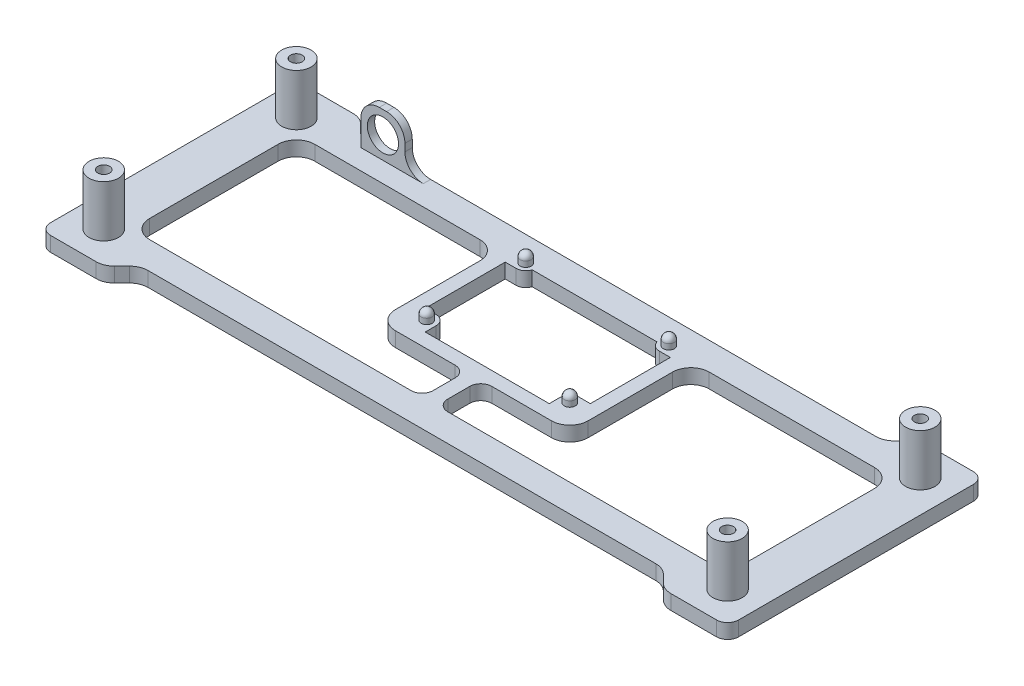
from build123d import *

# Parameters (mm, degrees)
SKETCH2_R           = 1.6
SKETCH2_W           = 162.5
SKETCH2_H           = 45
BOSS_EXTRUDE2_DEPTH = 4
FILLET3_R           = 3
FILLET4_R           = 5
BOSS_EXTRUDE3_DEPTH = 4
FILLET5_R           = 5
SKETCH7_W           = 12
SKETCH7_H           = 2
BOSS_EXTRUDE4_DEPTH = 12
CUT_EXTRUDE3_REACH  = 67
SKETCH8_R           = 4.25
FILLET6_R           = 5
FILLET7_R           = 3
SKETCH9_R           = 1.5
BOSS_EXTRUDE5_DEPTH = 3
FILLET8_R           = 1.5
SKETCH10_R          = 4
SKETCH10_R_2        = 1.6
BOSS_EXTRUDE6_DEPTH = 14


with BuildPart() as part:
    # Sketch2 → Boss-Extrude2 (new body)
    with BuildSketch(Plane(origin=(0, 0, 0), x_dir=(1, 0, 0), z_dir=(0, 1, 0))):
        Polygon((-93.75, -35), (-76.25, -35), (-71.25, -30), (71.25, -30), (76.25, -35), (93.75, -35), (93.75, 35), (76.25, 35), (71.25, 30), (-71.25, 30), (-76.25, 35), (-93.75, 35), align=None)
        with Locations((-85, 26.25)):
            Circle(SKETCH2_R, mode=Mode.SUBTRACT)
        with Locations((85, 26.25)):
            Circle(SKETCH2_R, mode=Mode.SUBTRACT)
        with Locations((85, -26.25)):
            Circle(SKETCH2_R, mode=Mode.SUBTRACT)
        with Locations((-85, -26.25)):
            Circle(SKETCH2_R, mode=Mode.SUBTRACT)
        Rectangle(SKETCH2_W, SKETCH2_H, mode=Mode.SUBTRACT)
    extrude(amount=BOSS_EXTRUDE2_DEPTH)

    # Fillet3
    fillet3_edges = [part.edges().sort_by_distance(p)[0] for p in [
        (-93.75, 2, -35),
        (93.75, 2, -35),
        (93.75, 2, 35),
        (-93.75, 2, 35),
    ]]
    fillet(fillet3_edges, radius=FILLET3_R)

    # Fillet4
    fillet4_edges = [part.edges().sort_by_distance(p)[0] for p in [
        (-76.25, 2, -35),
        (-71.25, 2, -30),
        (71.25, 2, -30),
        (76.25, 2, -35),
        (76.25, 2, 35),
        (71.25, 2, 30),
        (-71.25, 2, 30),
        (-76.25, 2, 35),
        (81.25, 2, -22.5),
        (-81.25, 2, -22.5),
        (-81.25, 2, 22.5),
        (81.25, 2, 22.5),
    ]]
    fillet(fillet4_edges, radius=FILLET4_R)

    # Sketch5 → Boss-Extrude3 (add)
    with BuildSketch(Plane(origin=(0, 0, 0), x_dir=(1, 0, 0), z_dir=(0, 1, 0))):
        Polygon((-26.25, -10.5), (-2, -10.5), (-2, -25.93943087), (2, -25.93943087), (2, -10.5), (26.25, -10.5), (26.25, 30), (-26.25, 30), align=None)
        with BuildLine():
            Line((-16.9, 26.25), (16.9, 26.25))
            Line((16.9, 26.25), (16.9, 23.25))
            ThreePointArc((16.9, 23.25), (17.661522369, 21.411522369), (19.5, 20.65))
            Line((19.5, 20.65), (22.5, 20.65))
            Line((22.5, 20.65), (22.5, -1.15))
            Line((22.5, -1.15), (19.5, -1.15))
            ThreePointArc((19.5, -1.15), (17.661522369, -1.911522369), (16.9, -3.75))
            Line((16.9, -3.75), (16.9, -6.75))
            Line((16.9, -6.75), (-16.9, -6.75))
            Line((-16.9, -6.75), (-16.9, -3.75))
            ThreePointArc((-16.9, -3.75), (-17.661522369, -1.911522369), (-19.5, -1.15))
            Line((-19.5, -1.15), (-22.5, -1.15))
            Line((-22.5, -1.15), (-22.5, 20.65))
            Line((-22.5, 20.65), (-19.5, 20.65))
            ThreePointArc((-19.5, 20.65), (-17.661522369, 21.411522369), (-16.9, 23.25))
            Line((-16.9, 23.25), (-16.9, 26.25))
        make_face(mode=Mode.SUBTRACT)
    extrude(amount=BOSS_EXTRUDE3_DEPTH)

    # Fillet5
    fillet5_edges = [part.edges().sort_by_distance(p)[0] for p in [
        (-26.25, 2, -22.5),
        (26.25, 2, -22.5),
        (26.25, 2, 10.5),
        (-26.25, 2, 10.5),
    ]]
    fillet(fillet5_edges, radius=FILLET5_R)

    # Sketch7 → Boss-Extrude4 (add)
    with BuildSketch(Plane(origin=(0, 4, 0), x_dir=(1, 0, 0), z_dir=(0, 1, 0))):
        with Locations((-63.178932188, 29)):
            Rectangle(SKETCH7_W, SKETCH7_H)
    extrude(amount=BOSS_EXTRUDE4_DEPTH)

    # Sketch8 → Cut-Extrude3 (cut, up to next)
    with BuildSketch(Plane(origin=(0, 0, -30), x_dir=(-1, 0, 0), z_dir=(0, 0, -1)), mode=Mode.PRIVATE) as cut_extrude3_sk1:
        with Locations((63.178932188, 10)):
            Circle(SKETCH8_R)
    cut_extrude3_tool1 = extrude(cut_extrude3_sk1.sketch, amount=-CUT_EXTRUDE3_REACH, mode=Mode.PRIVATE) & part.part
    add(cut_extrude3_tool1.solids().sort_by_distance((-63.178932, 10, -30))[0], mode=Mode.SUBTRACT)

    # Fillet6
    fillet6_edges = [part.edges().sort_by_distance(p)[0] for p in [
        (-57.178932188, 4, -29),
        (-69.178932188, 16, -29),
        (-57.178932188, 16, -29),
    ]]
    fillet(fillet6_edges, radius=FILLET6_R)

    # Fillet7
    fillet7_edges = [part.edges().sort_by_distance(p)[0] for p in [
        (2, 2, 22.5),
        (-2, 2, 22.5),
        (-2, 2, 10.5),
        (2, 2, 10.5),
    ]]
    fillet(fillet7_edges, radius=FILLET7_R)

    # Sketch9 → Boss-Extrude5 (add)
    with BuildSketch(Plane(origin=(0, 4, 0), x_dir=(1, 0, 0), z_dir=(0, 1, 0))):
        with Locations((-19.5, -3.75)):
            Circle(SKETCH9_R)
        with Locations((-19.5, 23.25)):
            Circle(SKETCH9_R)
        with Locations((19.5, 23.25)):
            Circle(SKETCH9_R)
        with Locations((19.5, -3.75)):
            Circle(SKETCH9_R)
    extrude(amount=BOSS_EXTRUDE5_DEPTH)

    # Fillet8
    fillet8_edges = [part.edges().sort_by_distance(p)[0] for p in [
        (-21, 7, 3.75),
        (-21, 7, -23.25),
        (18, 7, -23.25),
        (18, 7, 3.75),
    ]]
    fillet(fillet8_edges, radius=FILLET8_R)

    # Sketch10 → Boss-Extrude6 (add)
    with BuildSketch(Plane(origin=(0, 4, 0), x_dir=(1, 0, 0), z_dir=(0, 1, 0))):
        with Locations((-85, 26.25)):
            Circle(SKETCH10_R)
        with Locations((-85, 26.25)):
            Circle(SKETCH10_R_2, mode=Mode.SUBTRACT)
        with Locations((85, 26.25)):
            Circle(SKETCH10_R)
        with Locations((85, 26.25)):
            Circle(SKETCH10_R_2, mode=Mode.SUBTRACT)
        with Locations((85, -26.25)):
            Circle(SKETCH10_R)
        with Locations((85, -26.25)):
            Circle(SKETCH10_R_2, mode=Mode.SUBTRACT)
        with Locations((-85, -26.25)):
            Circle(SKETCH10_R)
        with Locations((-85, -26.25)):
            Circle(SKETCH10_R_2, mode=Mode.SUBTRACT)
    extrude(amount=BOSS_EXTRUDE6_DEPTH)


solid = part.part
